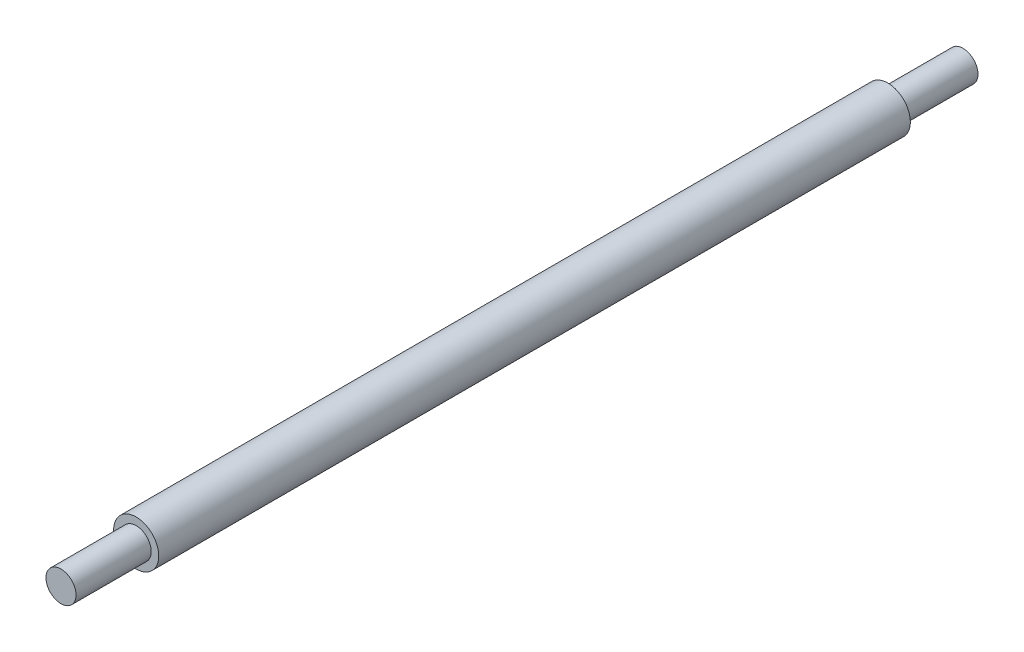
from build123d import *

# Parameters (mm, degrees)
SKETCH1_R           = 19.05
BOSS_EXTRUDE1_DEPTH = 635
SKETCH2_R           = 12.7
BOSS_EXTRUDE2_DEPTH = 63.5
SKETCH3_R           = 12.7
BOSS_EXTRUDE3_DEPTH = 63.5


with BuildPart() as part:
    # Sketch1 → Boss-Extrude1 (new body)
    with BuildSketch(Plane.XY):
        Circle(SKETCH1_R)
    extrude(amount=BOSS_EXTRUDE1_DEPTH)

    # Sketch2 → Boss-Extrude2 (add)
    with BuildSketch(Plane.XY.offset(635)):
        Circle(SKETCH2_R)
    extrude(amount=BOSS_EXTRUDE2_DEPTH)

    # Sketch3 → Boss-Extrude3 (add)
    with BuildSketch(Plane(origin=(0, 0, 0), x_dir=(-1, 0, 0), z_dir=(0, 0, -1))):
        Circle(SKETCH3_R)
    extrude(amount=BOSS_EXTRUDE3_DEPTH)


solid = part.part
